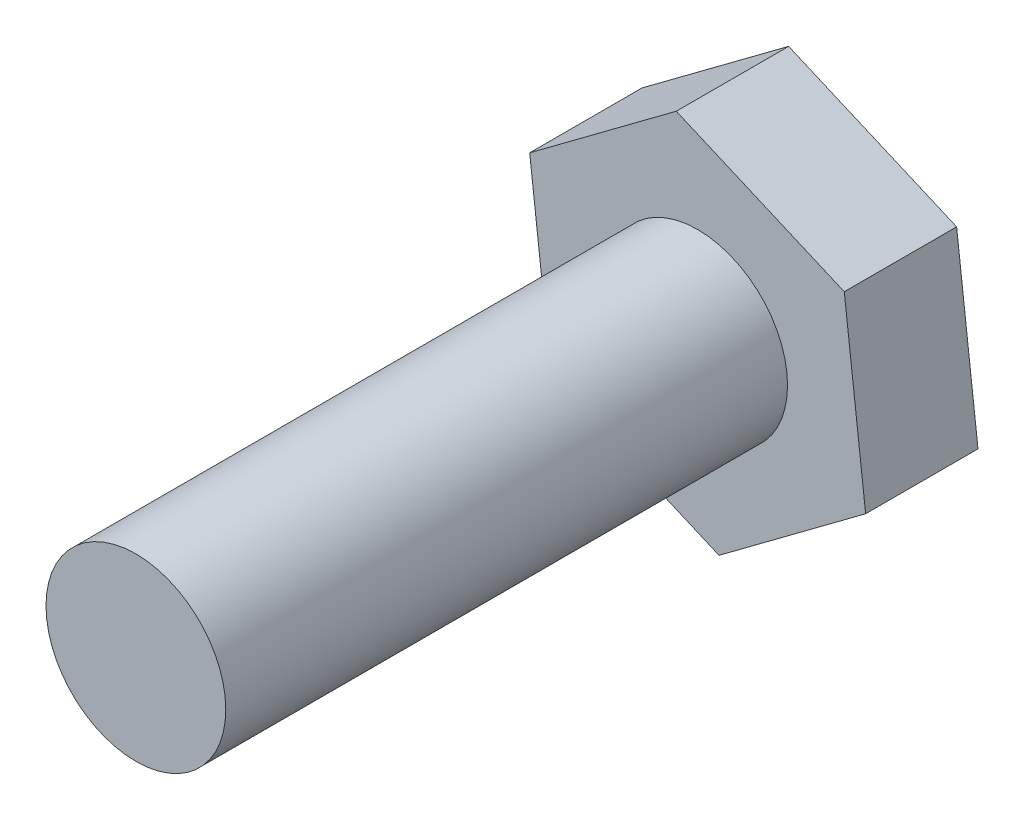
from build123d import *

# Parameters (mm, degrees)
BOSS_EXTRUDE1_DEPTH = 5
SKETCH2_R           = 4
BOSS_EXTRUDE2_DEPTH = 25


with BuildPart() as part:
    # Sketch1 → Boss-Extrude1 (new body)
    with BuildSketch(Plane.XY):
        Polygon((-0.950929855, 8.082903769), (-7.475464928, 3.217922473), (-6.524535072, -4.864981296), (0.950929855, -8.082903769), (7.475464928, -3.217922473), (6.524535072, 4.864981296), align=None)
    extrude(amount=BOSS_EXTRUDE1_DEPTH)

    # Sketch2 → Boss-Extrude2 (add)
    with BuildSketch(Plane.XY.offset(5)):
        Circle(SKETCH2_R)
    extrude(amount=BOSS_EXTRUDE2_DEPTH)


solid = part.part
